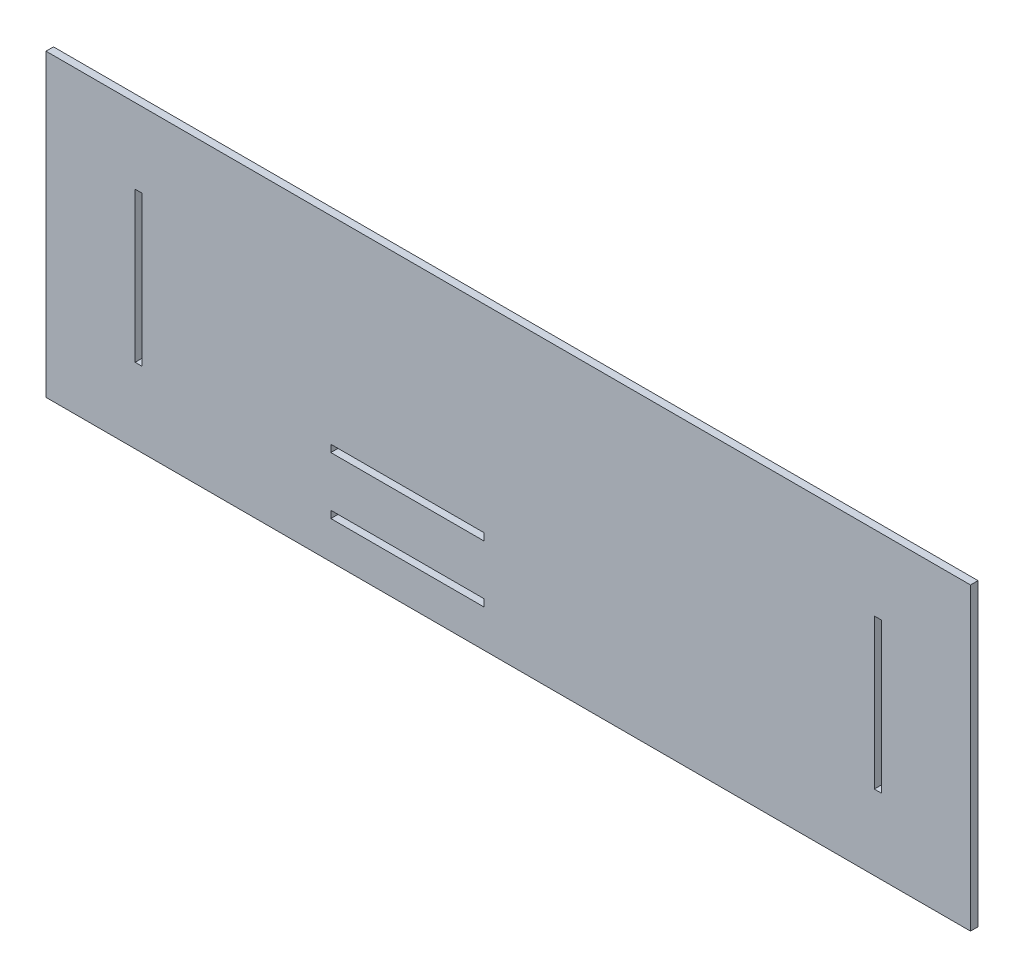
from build123d import *

# Parameters (mm, degrees)
SKETCH2_W           = 370
SKETCH2_H           = 120
SKETCH2_W_2         = 2.84
SKETCH2_H_2         = 60
SKETCH2_W_3         = 61.25
SKETCH2_H_3         = 2.88
BOSS_EXTRUDE1_DEPTH = 3


with BuildPart() as part:
    # Sketch2 → Boss-Extrude1 (new body)
    with BuildSketch(Plane.XY):
        Rectangle(SKETCH2_W, SKETCH2_H)
        with Locations((-147.92, 0)):
            Rectangle(SKETCH2_W_2, SKETCH2_H_2, mode=Mode.SUBTRACT)
        with Locations((147.92, 0)):
            Rectangle(SKETCH2_W_2, SKETCH2_H_2, mode=Mode.SUBTRACT)
        with Locations((-40.375, -43.56)):
            Rectangle(SKETCH2_W_3, SKETCH2_H_3, mode=Mode.SUBTRACT)
        with Locations((-40.375, -20.68)):
            Rectangle(SKETCH2_W_3, SKETCH2_H_3, mode=Mode.SUBTRACT)
    extrude(amount=BOSS_EXTRUDE1_DEPTH)


solid = part.part
